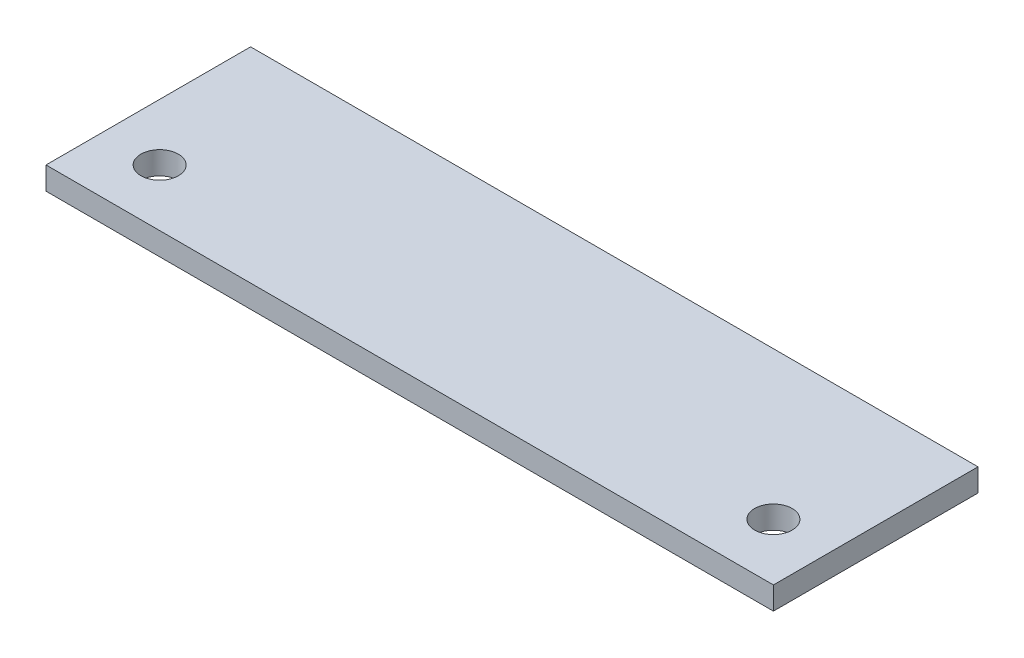
from build123d import *

# Parameters (mm, degrees)
SKETCH1_W           = 406.4
SKETCH1_H           = 114.3
BOSS_EXTRUDE1_DEPTH = 12.7
CUT_EXTRUDE1_REACH  = 14.7
SKETCH2_R           = 10.4775


with BuildPart() as part:
    # Sketch1 → Boss-Extrude1 (new body)
    with BuildSketch(Plane(origin=(0, 0, 0), x_dir=(1, 0, 0), z_dir=(0, 1, 0))):
        with Locations((203.2, 57.15)):
            Rectangle(SKETCH1_W, SKETCH1_H)
    extrude(amount=BOSS_EXTRUDE1_DEPTH)

    # Sketch2 → Cut-Extrude1 (cut, up to next)
    with BuildSketch(Plane(origin=(0, 12.7, 0), x_dir=(1, 0, 0), z_dir=(0, 1, 0)), mode=Mode.PRIVATE) as cut_extrude1_sk1:
        with Locations((31.75, 31.75)):
            Circle(SKETCH2_R)
    cut_extrude1_tool1 = extrude(cut_extrude1_sk1.sketch, amount=-CUT_EXTRUDE1_REACH, mode=Mode.PRIVATE) & part.part
    add(cut_extrude1_tool1.solids().sort_by_distance((31.75, 12.7, -31.75))[0], mode=Mode.SUBTRACT)
    # Sketch2 → Cut-Extrude1 (cut, up to next)
    with BuildSketch(Plane(origin=(0, 12.7, 0), x_dir=(1, 0, 0), z_dir=(0, 1, 0)), mode=Mode.PRIVATE) as cut_extrude1_sk2:
        with Locations((374.65, 31.75)):
            Circle(SKETCH2_R)
    cut_extrude1_tool2 = extrude(cut_extrude1_sk2.sketch, amount=-CUT_EXTRUDE1_REACH, mode=Mode.PRIVATE) & part.part
    add(cut_extrude1_tool2.solids().sort_by_distance((374.65, 12.7, -31.75))[0], mode=Mode.SUBTRACT)


solid = part.part
